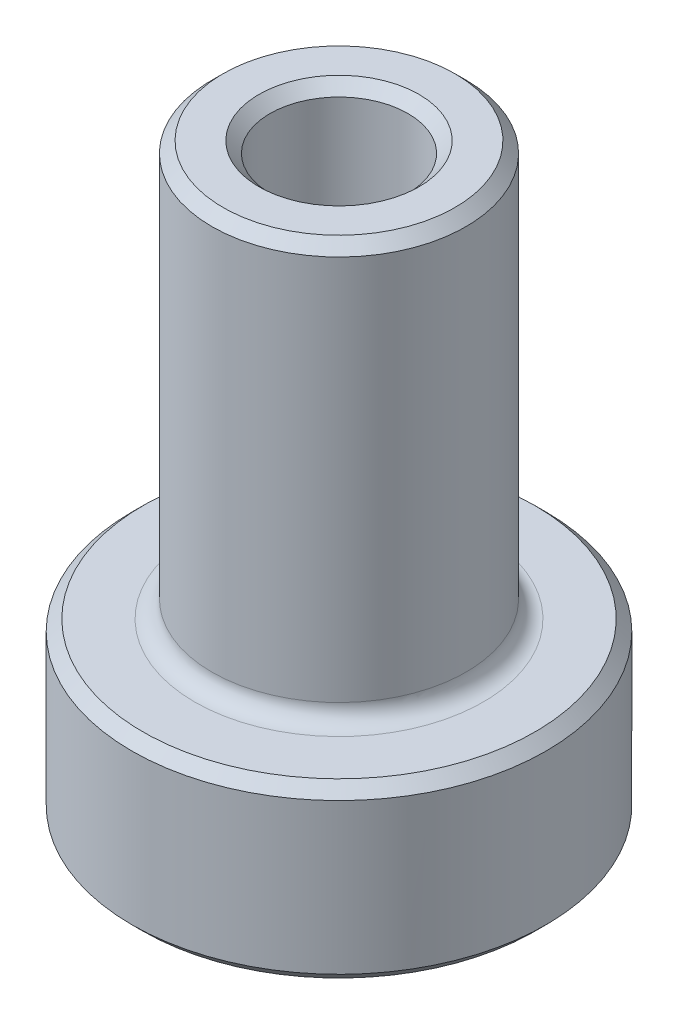
from build123d import *

# Parameters (mm, degrees)
CUT_EXTRUDE1_DEPTH = 2.38125
FILLET1_R          = 0.396875
FILLET2_R          = 0.79375
CHAMFER1_SIZE      = 0.254


with BuildPart() as part:
    # Sketch1 → Revolve1 (revolve)
    with BuildSketch(Plane.XY):
        Polygon((1.5875, 0), (4.7625, 0), (4.7625, 3.96875), (2.921, 3.96875), (2.921, 13.49375), (1.5875, 13.49375), align=None)
    revolve(axis=Axis((0, 7.886499903, 0), (0, -1, 0)))

    # Sketch2 → Cut-Extrude1 (cut)
    with BuildSketch(Plane.XZ):
        Polygon((1.75976362, 3.048), (-1.75976362, 3.048), (-3.519527241, 0), (-1.75976362, -3.048), (1.75976362, -3.048), (3.519527241, 0), align=None)
    extrude(amount=-CUT_EXTRUDE1_DEPTH, mode=Mode.SUBTRACT)

    # Fillet1
    fillet1_edges = [part.edges().sort_by_distance(p)[0] for p in [
        (-2.921, 3.96875, 0),
    ]]
    fillet(fillet1_edges, radius=FILLET1_R)

    # Fillet2
    fillet2_edges = [part.edges().sort_by_distance(p)[0] for p in [
        (2.639645431, 2.38125, 1.524),
        (1.75976362, 1.190625, 3.048),
        (2.639645431, 2.38125, -1.524),
        (3.519527241, 1.190625, 0),
        (0, 2.38125, -3.048),
        (1.75976362, 1.190625, -3.048),
        (-2.639645431, 2.38125, -1.524),
        (-1.75976362, 1.190625, -3.048),
        (-2.639645431, 2.38125, 1.524),
        (-3.519527241, 1.190625, 0),
        (0, 2.38125, 3.048),
        (-1.75976362, 1.190625, 3.048),
    ]]
    fillet(fillet2_edges, radius=FILLET2_R)

    # Chamfer1
    chamfer1_edges = [part.edges().sort_by_distance(p)[0] for p in [
        (-1.5875, 2.38125, 0),
        (2.639645431, 0, -1.524),
        (0, 0, -3.048),
        (-2.639645431, 0, -1.524),
        (-2.639645431, 0, 1.524),
        (-1.5875, 13.49375, 0),
        (2.639645431, 0, 1.524),
        (-2.921, 13.49375, 0),
        (0, 0, 3.048),
        (3.396733689, 0, 0),
        (1.698366844, 0, -2.941657664),
        (-1.698366844, 0, -2.941657664),
        (-3.396733689, 0, 0),
        (1.698366844, 0, 2.941657664),
        (-1.698366844, 0, 2.941657664),
        (-4.7625, 3.96875, 0),
        (-4.7625, 0, 0),
    ]]
    chamfer(chamfer1_edges, length=CHAMFER1_SIZE)


solid = part.part
